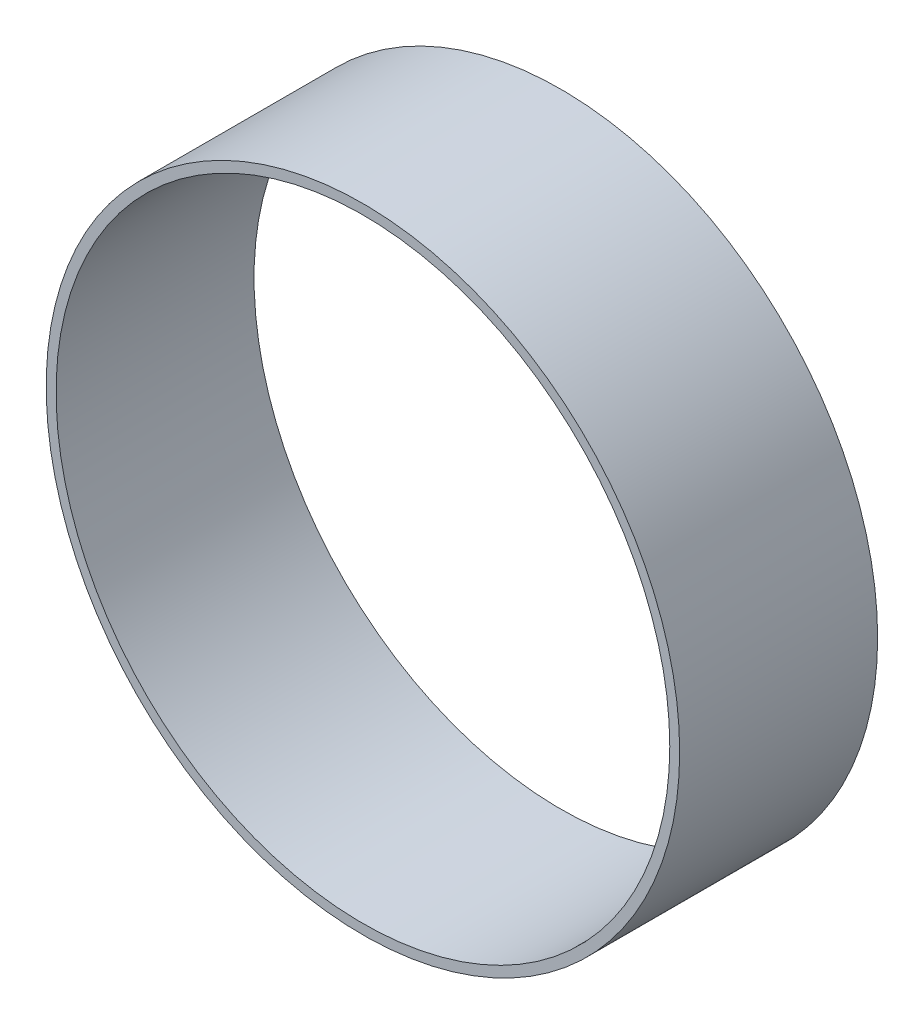
from build123d import *

# Parameters (mm, degrees)
ESQUISSE1_R             = 80
BOSS_EXTRU_1_DEPTH      = 50
ESQUISSE2_R             = 77.5
ENL_V_MAT_EXTRU_1_DEPTH = 50


with BuildPart() as part:
    # Esquisse1 → Boss.-Extru.1 (new body)
    with BuildSketch(Plane.XY):
        Circle(ESQUISSE1_R)
    extrude(amount=BOSS_EXTRU_1_DEPTH)

    # Esquisse2 → Enlèv. mat.-Extru.1 (cut)
    with BuildSketch(Plane.XY.offset(50)):
        Circle(ESQUISSE2_R)
    extrude(amount=-ENL_V_MAT_EXTRU_1_DEPTH, mode=Mode.SUBTRACT)


solid = part.part
